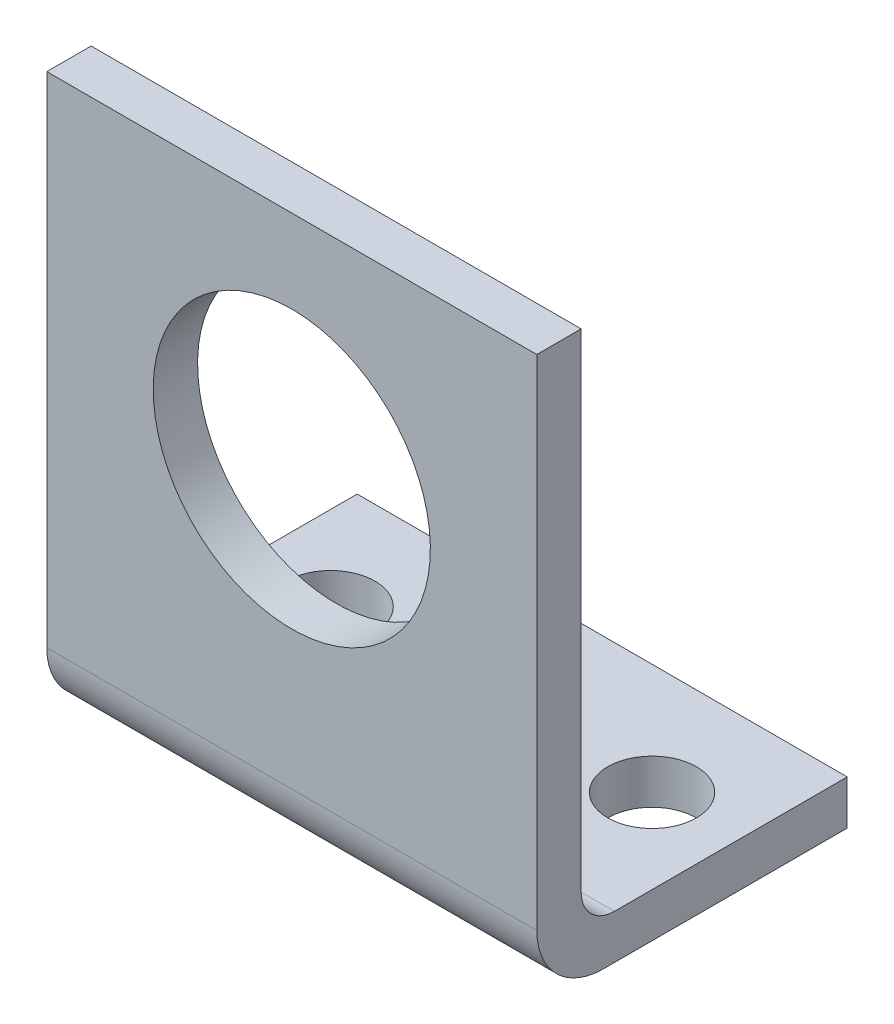
from build123d import *

# Parameters (mm, degrees)
BOSS_EXTRU_1_DEPTH      = 22.1
ESQUISSE2_R             = 2
ENL_V_MAT_EXTRU_1_DEPTH = 3
ESQUISSE3_R             = 6.25
ENL_V_MAT_EXTRU_2_DEPTH = 3


with BuildPart() as part:
    # Esquisse1 → Boss.-Extru.1 (new body)
    with BuildSketch(Plane(origin=(0, 0, 0), x_dir=(0, 0, -1), z_dir=(1, 0, 0))):
        with BuildLine():
            Line((0, 25.5), (0, 3))
            ThreePointArc((0, 3), (0.878679656, 0.878679656), (3, 0))
            Line((3, 0), (14, 0))
            Line((14, 0), (14, 2))
            Line((14, 2), (3.5, 2))
            ThreePointArc((3.5, 2), (2.439339828, 2.439339828), (2, 3.5))
            Line((2, 3.5), (2, 25.5))
            Line((2, 25.5), (0, 25.5))
        make_face()
    extrude(amount=BOSS_EXTRU_1_DEPTH)

    # Esquisse2 → Enlèv. mat.-Extru.1 (cut, through all)
    with BuildSketch(Plane(origin=(0, 2, 0), x_dir=(1, 0, 0), z_dir=(0, 1, 0))):
        with Locations((3.8, 9)):
            Circle(ESQUISSE2_R)
        with Locations((18.3, 9)):
            Circle(ESQUISSE2_R)
    extrude(amount=-ENL_V_MAT_EXTRU_1_DEPTH, mode=Mode.SUBTRACT)

    # Esquisse3 → Enlèv. mat.-Extru.2 (cut, through all)
    with BuildSketch(Plane(origin=(0, 0, -2), x_dir=(-1, 0, 0), z_dir=(0, 0, -1))):
        with Locations((-11.05, 15.5)):
            Circle(ESQUISSE3_R)
    extrude(amount=-ENL_V_MAT_EXTRU_2_DEPTH, mode=Mode.SUBTRACT)


solid = part.part
